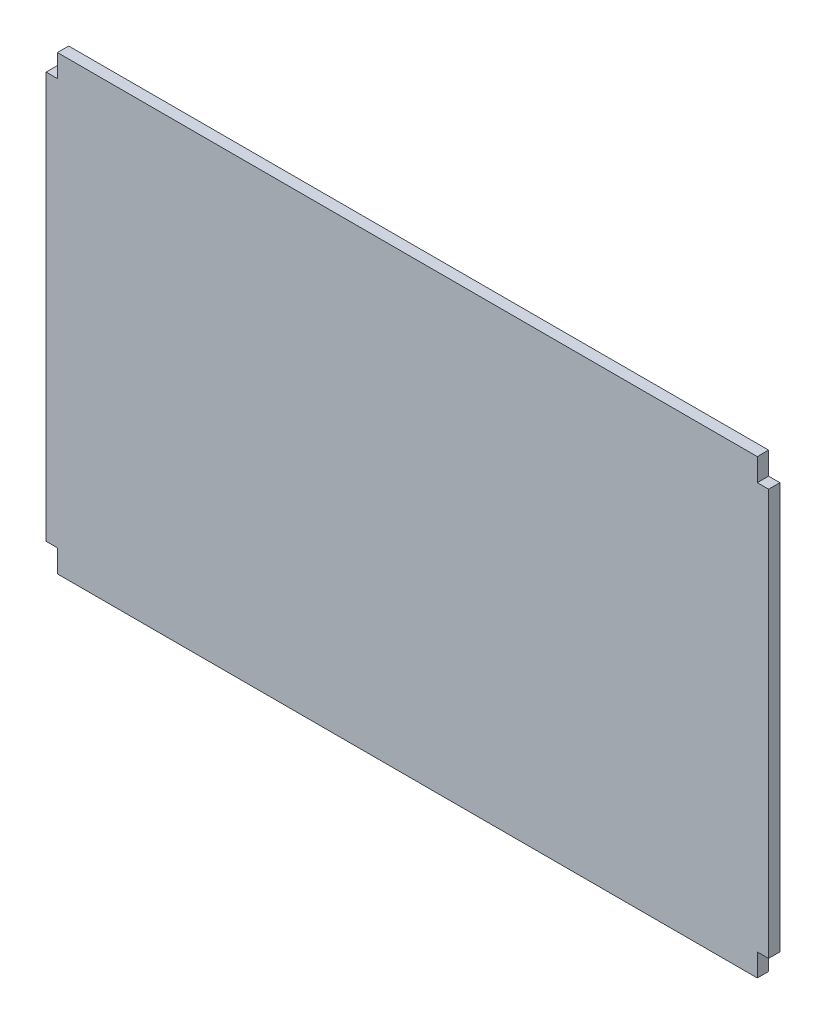
from build123d import *

# Parameters (mm, degrees)
BOSS_EXTRUDE1_DEPTH = 3.175


with BuildPart() as part:
    # Sketch2 → Boss-Extrude1 (new body)
    with BuildSketch(Plane.XY):
        Polygon((0, 120.65), (0, 127), (196.85, 127), (196.85, 120.65), (200.025, 120.65), (200.025, 6.35), (196.85, 6.35), (196.85, 0), (0, 0), (0, 6.35), (-3.175, 6.35), (-3.175, 120.65), align=None)
    extrude(amount=BOSS_EXTRUDE1_DEPTH)


solid = part.part
